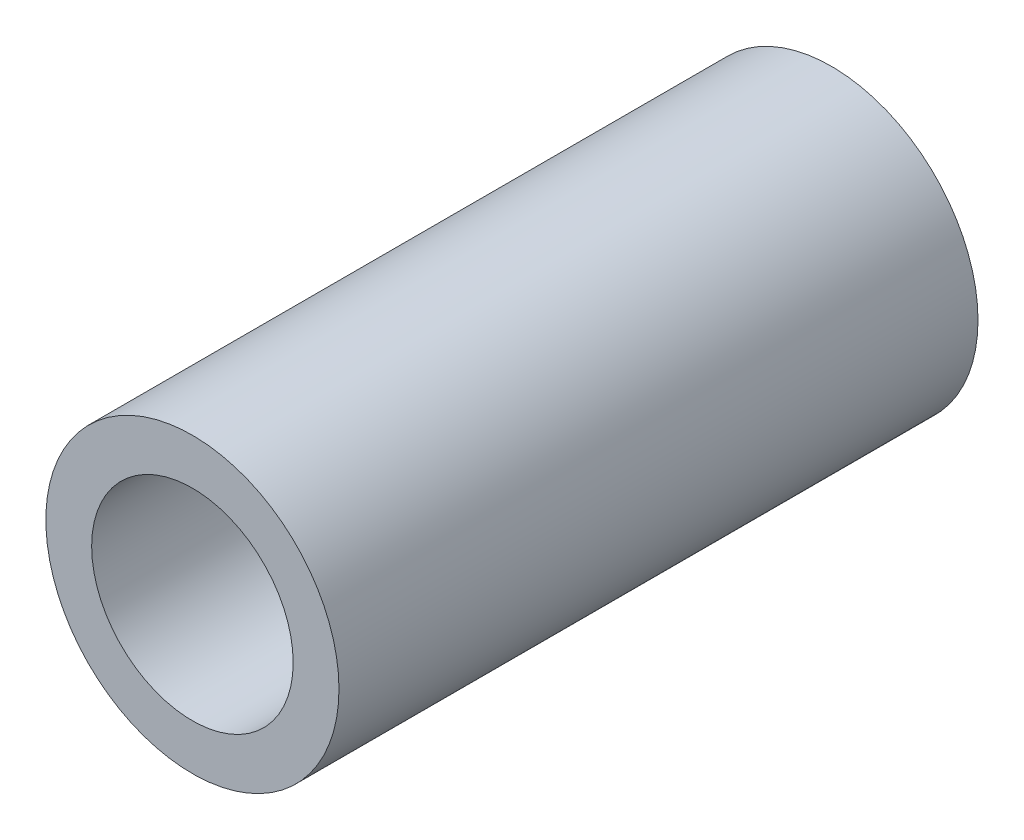
from build123d import *

# Parameters (mm, degrees)
SKETCH_1_R      = 4
SKETCH_1_R_2    = 2.75
EXTRUDE_1_DEPTH = 17.44


with BuildPart() as part:
    # ｽｹｯﾁ1 → ﾎﾞｽ - 押し出し1 (new body)
    with BuildSketch(Plane.XY):
        Circle(SKETCH_1_R)
        Circle(SKETCH_1_R_2, mode=Mode.SUBTRACT)
    extrude(amount=EXTRUDE_1_DEPTH)


solid = part.part
